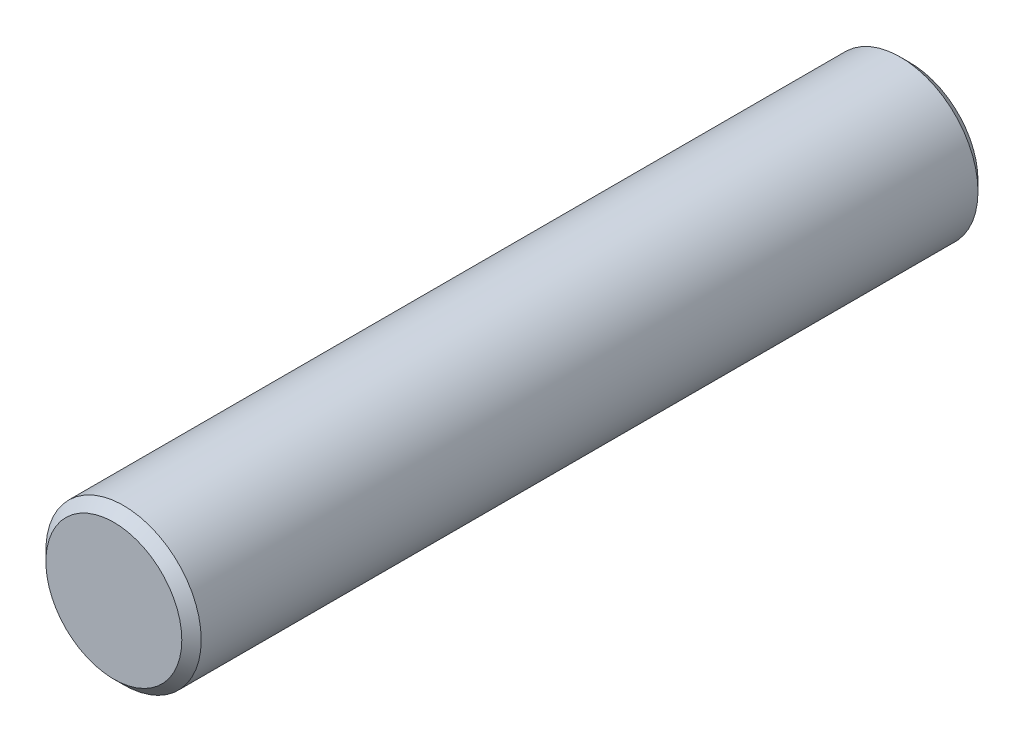
from build123d import *

# Parameters (mm, degrees)
SKETCH2_R           = 8
BOSS_EXTRUDE1_DEPTH = 41
CHAMFER1_SIZE       = 1


with BuildPart() as part:
    # Sketch2 → Boss-Extrude1 (new body, symmetric)
    with BuildSketch(Plane.XY):
        Circle(SKETCH2_R)
    extrude(amount=BOSS_EXTRUDE1_DEPTH, both=True)

    # Chamfer1
    chamfer1_edges = [part.edges().sort_by_distance(p)[0] for p in [
        (-8, 0, -41),
        (-8, 0, 41),
    ]]
    chamfer(chamfer1_edges, length=CHAMFER1_SIZE)


solid = part.part
